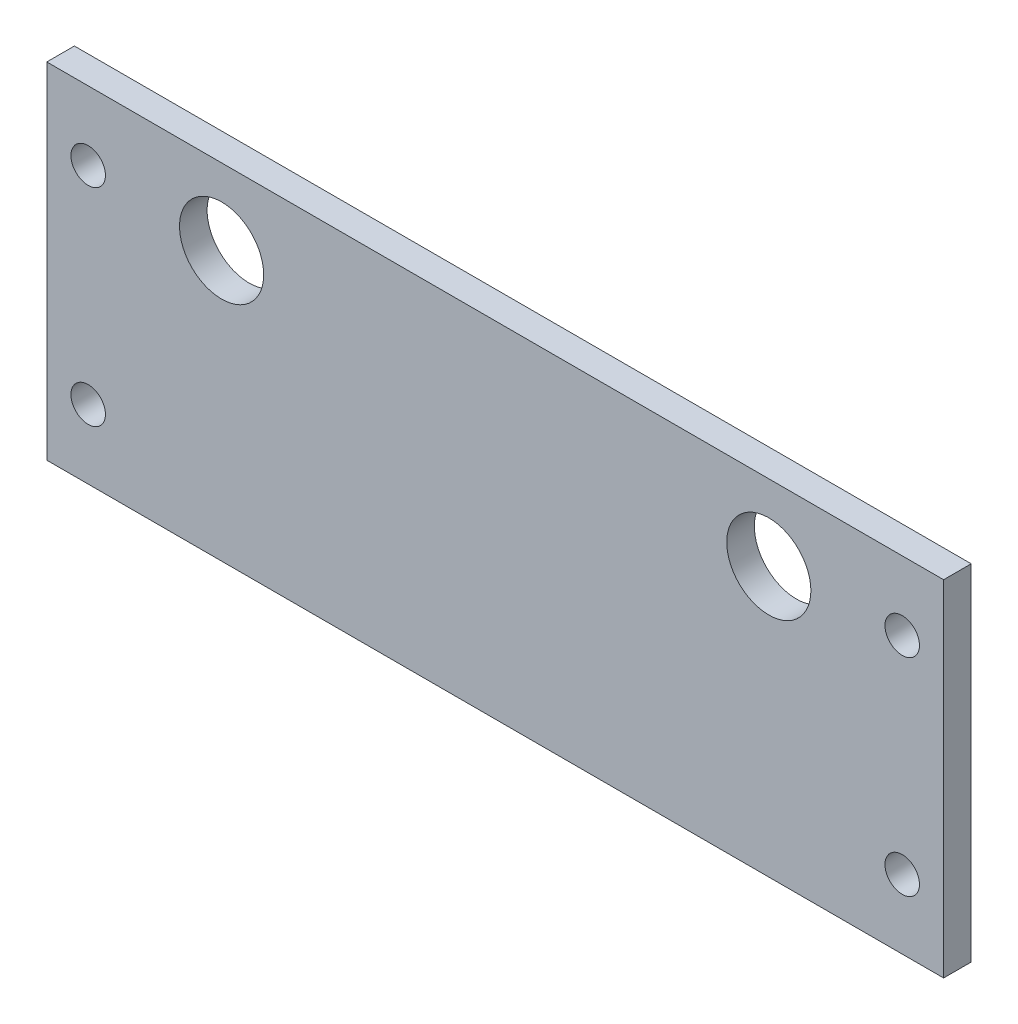
from build123d import *

# Parameters (mm, degrees)
SKETCH_1_W      = 65
SKETCH_1_H      = 25
SKETCH_1_R      = 3.05
EXTRUDE_1_DEPTH = 2
M3X0_5_1_D      = 2.5
M3X0_5_1_DEPTH  = 8.5
M3X0_5_1_TIP    = 0.751075774


with BuildPart() as part:
    # ｽｹｯﾁ1 → ﾎﾞｽ - 押し出し1 (new body)
    with BuildSketch(Plane.XY):
        Rectangle(SKETCH_1_W, SKETCH_1_H)
        with Locations((-19.83, 7)):
            Circle(SKETCH_1_R, mode=Mode.SUBTRACT)
        with Locations((19.83, 7)):
            Circle(SKETCH_1_R, mode=Mode.SUBTRACT)
    extrude(amount=EXTRUDE_1_DEPTH)

    # M3x0.5 ねじ穴1
    with Locations(Plane(origin=(-29.5, 7.5, 2), x_dir=(1, 0, 0), z_dir=(0, 0, 1))):
        with Locations((0, 0), (0, -15), (59, 0), (59, -15)):
            Hole(M3X0_5_1_D / 2, depth=M3X0_5_1_DEPTH)
            with Locations((0, 0, -(M3X0_5_1_DEPTH + M3X0_5_1_TIP / 2))):  # 118° drill point
                Cone(0, M3X0_5_1_D / 2, M3X0_5_1_TIP, mode=Mode.SUBTRACT)


solid = part.part
